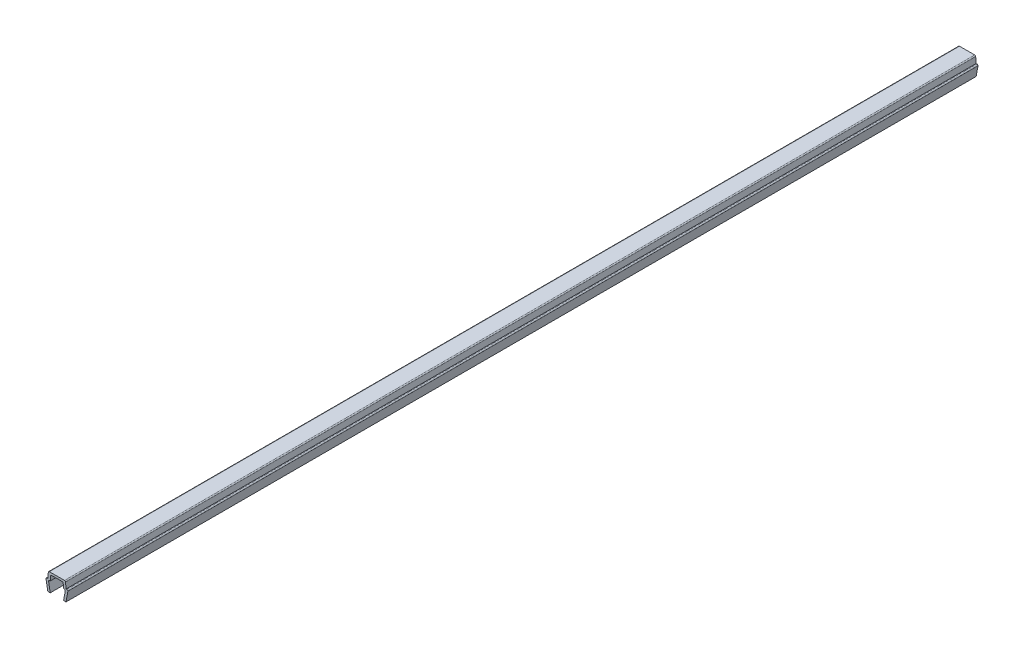
from build123d import *

# Parameters (mm, degrees)
BOSS_EXTRUDE1_DEPTH = 150


with BuildPart() as part:
    # Sketch1 → Boss-Extrude1 (new body, symmetric)
    with BuildSketch(Plane.XY):
        with BuildLine():
            Line((-3.6, 3.35), (-3, 0))
            Line((-3, 0), (-2.2, 0))
            Line((-2.2, 0), (-2.735217071, 2.988295315))
            ThreePointArc((-2.735217071, 2.988295315), (-2.659117427, 3.274614514), (-2.390699246, 3.4))
            Line((-2.390699246, 3.4), (-2.2, 3.4))
            Line((-2.2, 3.4), (-2.070472639, 4.88050451))
            ThreePointArc((-2.070472639, 4.88050451), (-1.958261067, 5.108047068), (-1.721804495, 5.2))
            Line((-1.721804495, 5.2), (1.721804495, 5.2))
            ThreePointArc((1.721804495, 5.2), (1.958261067, 5.108047068), (2.070472639, 4.88050451))
            Line((2.070472639, 4.88050451), (2.2, 3.4))
            Line((2.2, 3.4), (2.390699246, 3.4))
            ThreePointArc((2.390699246, 3.4), (2.659117427, 3.274614514), (2.735217071, 2.988295315))
            Line((2.735217071, 2.988295315), (2.2, 0))
            Line((2.2, 0), (3, 0))
            Line((3, 0), (3.6, 3.35))
            ThreePointArc((3.6, 3.35), (3.497487373, 3.597487373), (3.25, 3.7))
            Line((3.25, 3.7), (3, 3.7))
            Line((3, 3.7), (2.835477174, 5.58050451))
            ThreePointArc((2.835477174, 5.58050451), (2.723265602, 5.808047068), (2.486809029, 5.9))
            Line((2.486809029, 5.9), (-2.486809029, 5.9))
            ThreePointArc((-2.486809029, 5.9), (-2.723265602, 5.808047068), (-2.835477174, 5.58050451))
            Line((-2.835477174, 5.58050451), (-3, 3.7))
            Line((-3, 3.7), (-3.25, 3.7))
            ThreePointArc((-3.25, 3.7), (-3.497487373, 3.597487373), (-3.6, 3.35))
        make_face()
    extrude(amount=BOSS_EXTRUDE1_DEPTH, both=True)


solid = part.part
